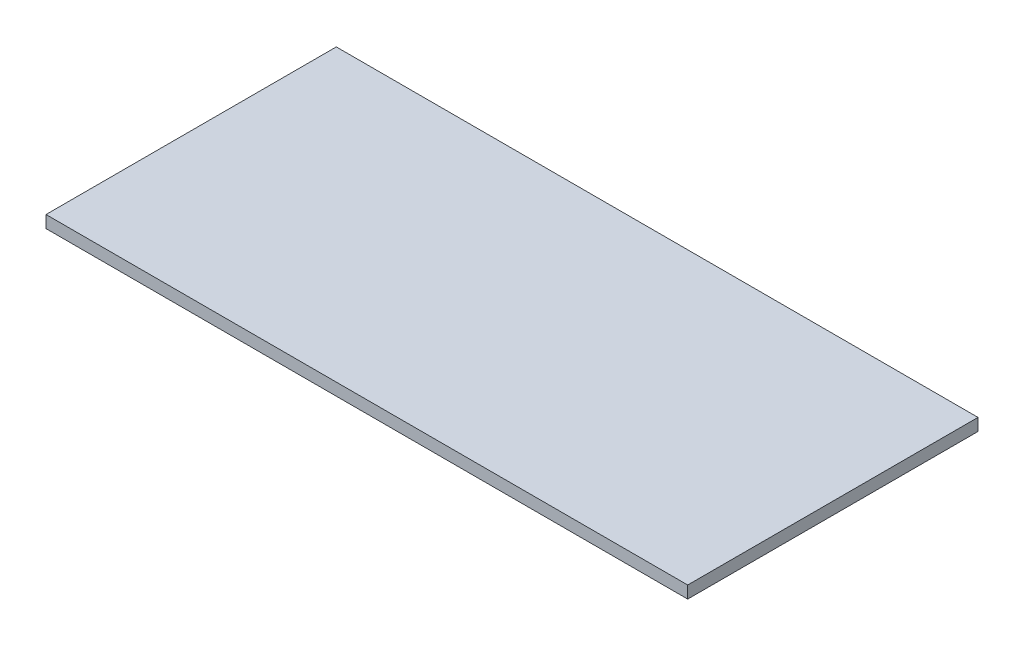
from build123d import *

# Parameters (mm, degrees)
SKETCH1_W           = 210
SKETCH1_H           = 95
BOSS_EXTRUDE1_DEPTH = 4


with BuildPart() as part:
    # Sketch1 → Boss-Extrude1 (new body)
    with BuildSketch(Plane(origin=(0, 0, 0), x_dir=(1, 0, 0), z_dir=(0, 1, 0))):
        Rectangle(SKETCH1_W, SKETCH1_H)
    extrude(amount=BOSS_EXTRUDE1_DEPTH)


solid = part.part
